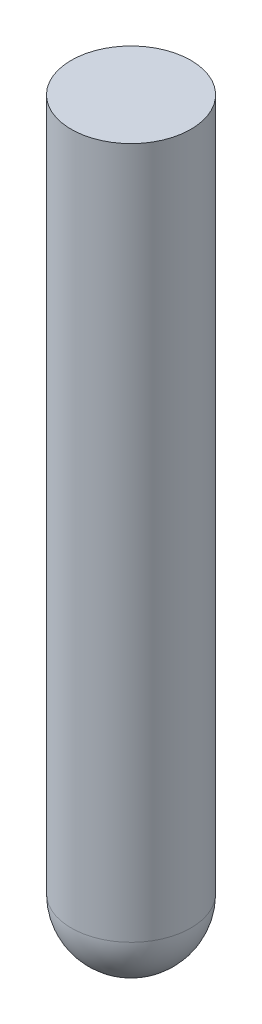
from build123d import *

# Parameters (mm, degrees)
SWEEP1_PROFILE_R = 0.5


with BuildPart() as part:
    # Sweep1: sweep along a path in Sketch1
    with BuildLine(Plane(origin=(0, 0, 0), x_dir=(0, 0, -1), z_dir=(1, 0, 0))) as sweep1_path:
        Line((75.699870549, 32.124625667), (75.699870549, 26.343116542))
    # Sweep1 profile (on start of the path) → Sweep1 (sweep)
    with BuildSketch(Plane(origin=(0, 32.124625667, -75.699870549), x_dir=(0, 0, -1), z_dir=(0, -1, 0))):
        Circle(SWEEP1_PROFILE_R)
    sweep(path=sweep1_path.line)

    # Sketch14 → Revolve4 (revolve)
    with BuildSketch(Plane(origin=(0, 0, 0), x_dir=(0, 0, -1), z_dir=(1, 0, 0))):
        with BuildLine():
            Line((75.699870549, 26.843116542), (75.699870549, 25.843116542))
            ThreePointArc((75.699870549, 25.843116542), (75.199870549, 26.343116542), (75.699870549, 26.843116542))
        make_face()
    revolve(axis=Axis((0, 26.843116542, -75.699870549), (0, -1, 0)))


solid = part.part
